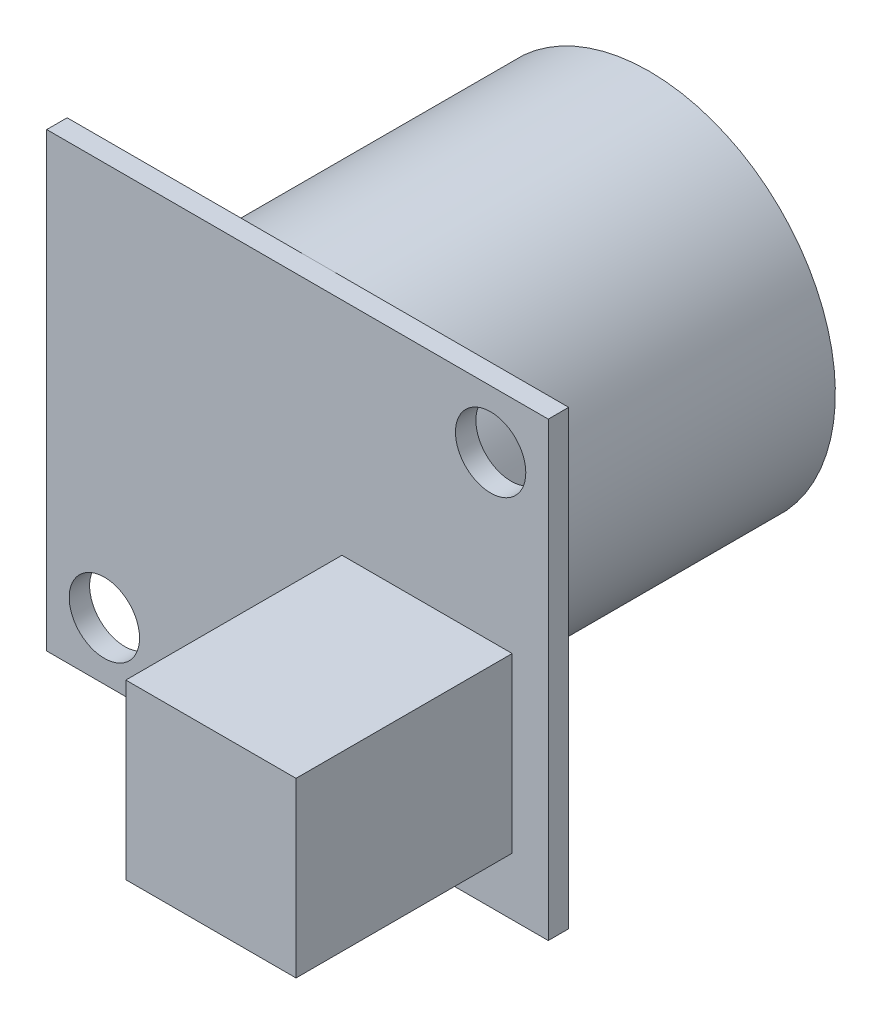
from build123d import *

# Parameters (mm, degrees)
SKETCH2_W           = 22.1
SKETCH2_H           = 19.9
SKETCH2_R           = 1.55
BOSS_EXTRUDE1_DEPTH = 0.9
SKETCH3_W           = 7.5
SKETCH3_H           = 7.62
BOSS_EXTRUDE2_DEPTH = 9.525
SKETCH4_R           = 8.2
BOSS_EXTRUDE3_DEPTH = 14.6


with BuildPart() as part:
    # Sketch2 → Boss-Extrude1 (new body)
    with BuildSketch(Plane.XY):
        Rectangle(SKETCH2_W, SKETCH2_H)
        with Locations((-8.51, -7.41)):
            Circle(SKETCH2_R, mode=Mode.SUBTRACT)
        with Locations((8.51, 7.41)):
            Circle(SKETCH2_R, mode=Mode.SUBTRACT)
    extrude(amount=BOSS_EXTRUDE1_DEPTH)

    # Sketch3 → Boss-Extrude2 (add)
    with BuildSketch(Plane.XY.offset(0.9)):
        with Locations((5.710174181, -3.6)):
            Rectangle(SKETCH3_W, SKETCH3_H)
    extrude(amount=BOSS_EXTRUDE2_DEPTH)

    # Sketch4 → Boss-Extrude3 (add)
    with BuildSketch(Plane(origin=(0, 0, 0), x_dir=(-1, 0, 0), z_dir=(0, 0, -1))):
        with Locations((0, 1.75)):
            Circle(SKETCH4_R)
    extrude(amount=BOSS_EXTRUDE3_DEPTH)


solid = part.part
